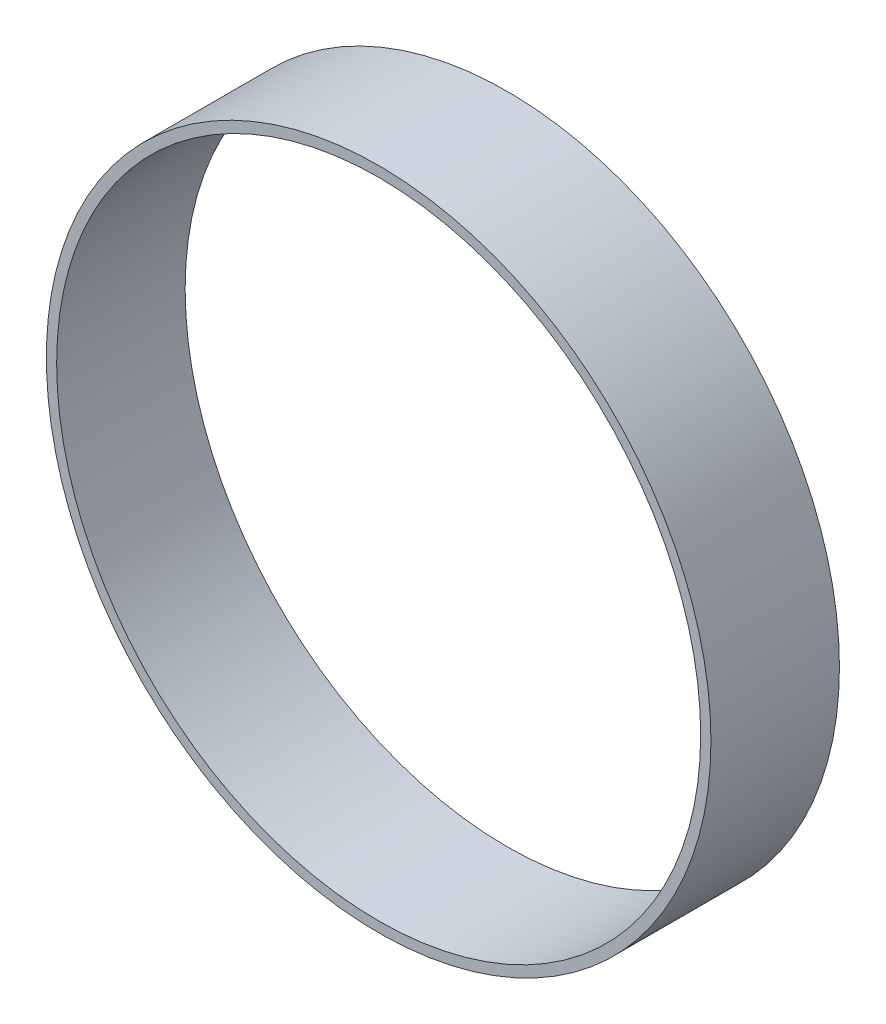
from build123d import *

# Parameters (mm, degrees)
SKETCH1_R           = 16.4211
SKETCH1_R_2         = 15.9131
BOSS_EXTRUDE1_DEPTH = 6.35


with BuildPart() as part:
    # Sketch1 → Boss-Extrude1 (new body)
    with BuildSketch(Plane.XY):
        Circle(SKETCH1_R)
        Circle(SKETCH1_R_2, mode=Mode.SUBTRACT)
    extrude(amount=BOSS_EXTRUDE1_DEPTH)


solid = part.part
